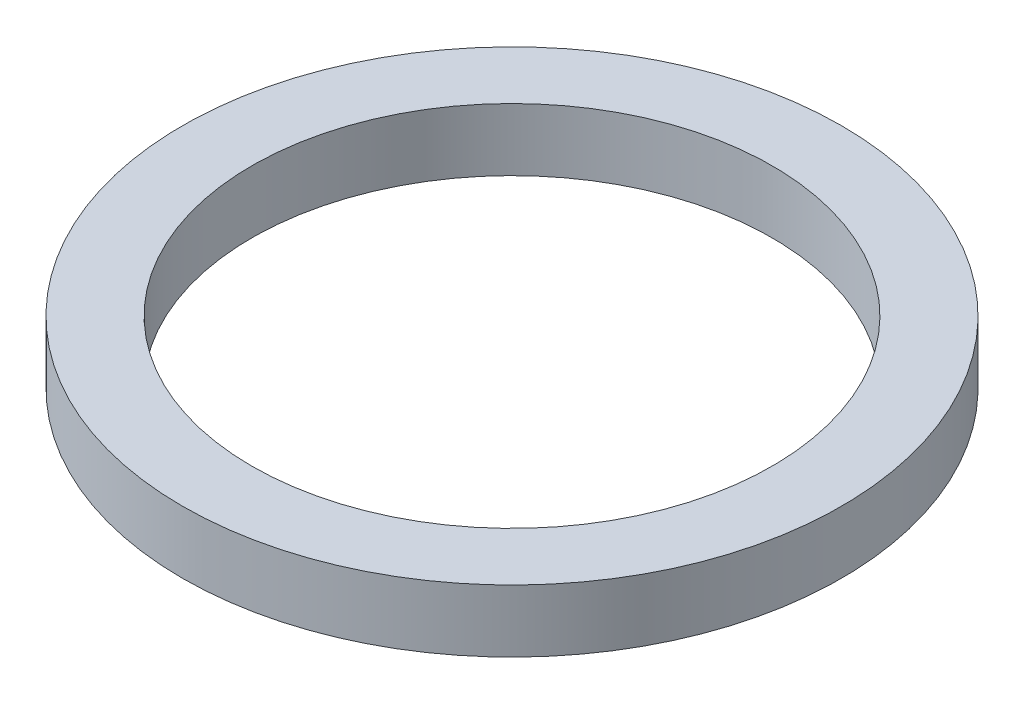
from build123d import *

# Parameters (mm, degrees)
SKETCH1_R           = 47.5
SKETCH1_R_2         = 37.5
BOSS_EXTRUDE1_DEPTH = 9


with BuildPart() as part:
    # Sketch1 → Boss-Extrude1 (new body)
    with BuildSketch(Plane(origin=(0, 0, 0), x_dir=(1, 0, 0), z_dir=(0, 1, 0))):
        Circle(SKETCH1_R)
        Circle(SKETCH1_R_2, mode=Mode.SUBTRACT)
    extrude(amount=BOSS_EXTRUDE1_DEPTH)


solid = part.part
